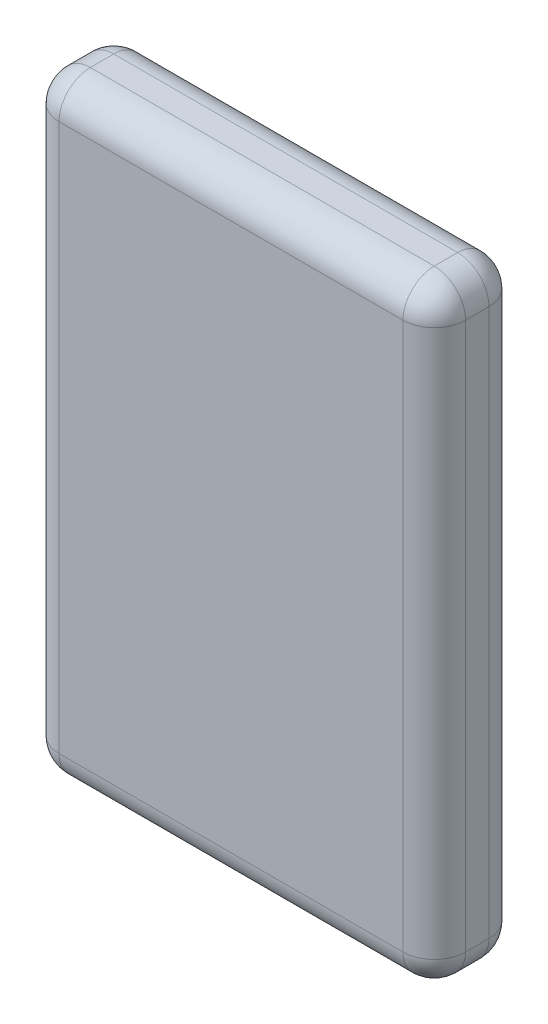
from build123d import *

# Parameters (mm, degrees)
BOSS_EXTRUDE1_START = 2.2
SKETCH1_W           = 26
SKETCH1_H           = 39
BOSS_EXTRUDE1_DEPTH = 5.5
FILLET1_R           = 2


with BuildPart() as part:
    # Sketch1 → Boss-Extrude1 (new body)
    with BuildSketch(Plane.XY.offset(BOSS_EXTRUDE1_START)):
        with Locations((0, 2.225783695)):
            Rectangle(SKETCH1_W, SKETCH1_H)
    extrude(amount=BOSS_EXTRUDE1_DEPTH)

    # Fillet1
    fillet1_edges = [part.edges().sort_by_distance(p)[0] for p in [
        (-13, 2.225783695, 7.7),
        (0, -17.274216305, 7.7),
        (13, 2.225783695, 7.7),
        (0, -17.274216305, 2.2),
        (-13, 2.225783695, 2.2),
        (0, 21.725783695, 2.2),
        (13, 2.225783695, 2.2),
        (13, -17.274216305, 4.95),
        (-13, -17.274216305, 4.95),
        (-13, 21.725783695, 4.95),
        (13, 21.725783695, 4.95),
        (0, 21.725783695, 7.7),
    ]]
    fillet(fillet1_edges, radius=FILLET1_R)


solid = part.part
